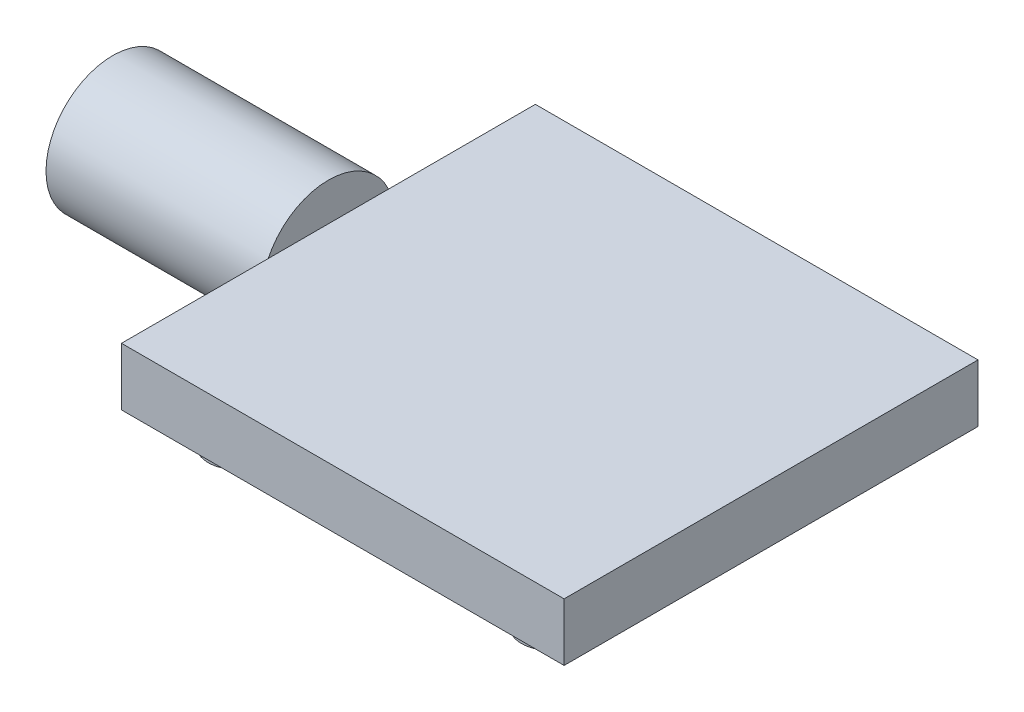
from build123d import *

# Parameters (mm, degrees)
SKETCH1_W           = 43.1
SKETCH1_H           = 40.3
BOSS_EXTRUDE1_DEPTH = 5.62
SKETCH2_R           = 2.75
SKETCH2_R_2         = 1.75
BOSS_EXTRUDE2_DEPTH = 8
SKETCH3_R           = 6.5
BOSS_EXTRUDE3_DEPTH = 21


with BuildPart() as part:
    # Sketch1 → Boss-Extrude1 (new body)
    with BuildSketch(Plane(origin=(0, 0, 0), x_dir=(1, 0, 0), z_dir=(0, 1, 0))):
        Rectangle(SKETCH1_W, SKETCH1_H)
    extrude(amount=BOSS_EXTRUDE1_DEPTH)

    # Sketch2 → Boss-Extrude2 (add)
    with BuildSketch(Plane(origin=(0, 5.62, 0), x_dir=(1, 0, 0), z_dir=(0, 1, 0))):
        with Locations((-15.25, 15.25)):
            Circle(SKETCH2_R)
        with Locations((-15.25, 15.25)):
            Circle(SKETCH2_R_2, mode=Mode.SUBTRACT)
        with Locations((15.25, 15.25)):
            Circle(SKETCH2_R)
        with Locations((15.25, 15.25)):
            Circle(SKETCH2_R_2, mode=Mode.SUBTRACT)
        with Locations((15.25, -15.25)):
            Circle(SKETCH2_R)
        with Locations((15.25, -15.25)):
            Circle(SKETCH2_R_2, mode=Mode.SUBTRACT)
        with Locations((-15.25, -15.25)):
            Circle(SKETCH2_R)
        with Locations((-15.25, -15.25)):
            Circle(SKETCH2_R_2, mode=Mode.SUBTRACT)
    extrude(amount=-BOSS_EXTRUDE2_DEPTH)

    # Sketch3 → Boss-Extrude3 (add)
    with BuildSketch(Plane.ZY.offset(21.55)):
        with Locations((0, 2.81)):
            Circle(SKETCH3_R)
    extrude(amount=BOSS_EXTRUDE3_DEPTH)


solid = part.part
